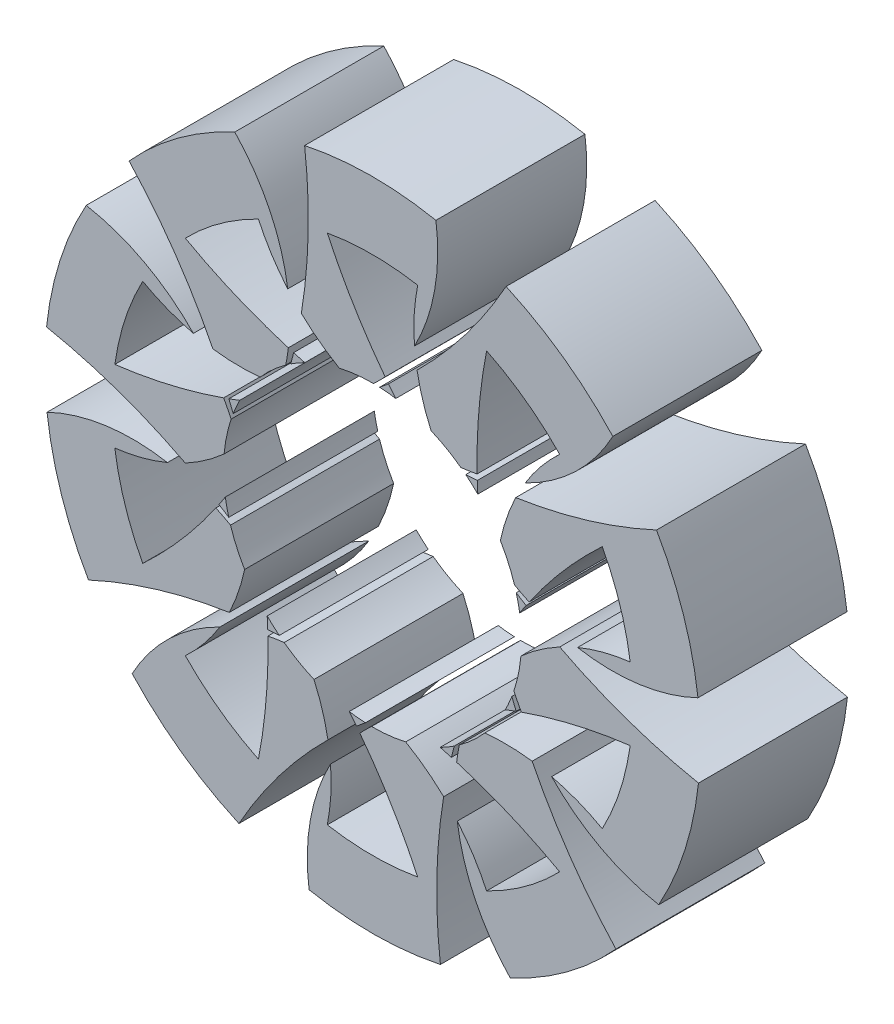
from build123d import *

# Parameters (mm, degrees)
SKETCH1_R           = 13.2
SKETCH1_R_2         = 6
BOSS_EXTRUDE1_DEPTH = 6
CUT_EXTRUDE1_DEPTH  = 7
CIRPATTERN1_COUNT   = 10


with BuildPart() as part:
    # Sketch1 → Boss-Extrude1 (new body)
    with BuildSketch(Plane.XY):
        Circle(SKETCH1_R)
        Circle(SKETCH1_R_2, mode=Mode.SUBTRACT)
    extrude(amount=BOSS_EXTRUDE1_DEPTH)

    # Sketch2 → Cut-Extrude1 (cut, through all)
    with BuildSketch(Plane.XY.offset(6)):
        with BuildLine():
            ThreePointArc((-2.819851171, 12.895287487), (0, 13.2), (2.819851171, 12.895287487))
            ThreePointArc((2.819851171, 12.895287487), (17.084333094, 5.874504435), (1.819851171, 10.32))
            ThreePointArc((1.819851171, 10.32), (0, 10.479229852), (-1.819851171, 10.32))
            ThreePointArc((-1.819851171, 10.32), (36.729469452, 26.770735562), (-2.819851171, 12.895287487))
        make_face()
    cut_extrude1 = extrude(amount=-CUT_EXTRUDE1_DEPTH, mode=Mode.SUBTRACT)

    # CirPattern1: Cut-Extrude1 ×10 about axis
    cirpattern1_axis = Axis((0, 0, 0), (0, 0, 1))
    for i in range(1, CIRPATTERN1_COUNT):
        add(cut_extrude1.rotate(cirpattern1_axis, i * 360 / CIRPATTERN1_COUNT), mode=Mode.SUBTRACT)


solid = part.part
